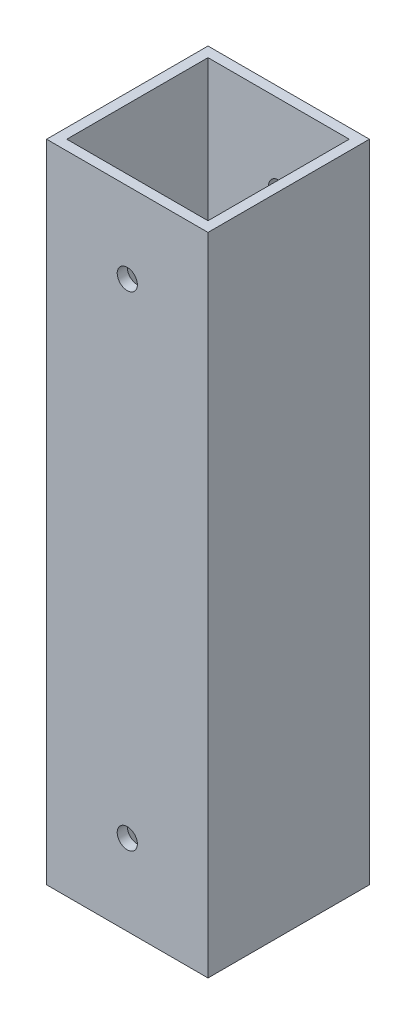
from build123d import *

# Parameters (mm, degrees)
SKETCH1_W           = 25.4
SKETCH1_H           = 25.4
SKETCH1_W_2         = 22.225
SKETCH1_H_2         = 22.225
BOSS_EXTRUDE1_DEPTH = 101.6
SKETCH2_R           = 1.5875
CUT_EXTRUDE1_DEPTH  = 25.4


with BuildPart() as part:
    # Sketch1 → Boss-Extrude1 (new body)
    with BuildSketch(Plane(origin=(0, 0, 0), x_dir=(1, 0, 0), z_dir=(0, 1, 0))):
        Rectangle(SKETCH1_W, SKETCH1_H)
        Rectangle(SKETCH1_W_2, SKETCH1_H_2, mode=Mode.SUBTRACT)
    extrude(amount=BOSS_EXTRUDE1_DEPTH)

    # Sketch2 → Cut-Extrude1 (cut)
    with BuildSketch(Plane(origin=(0, 0, -12.7), x_dir=(-1, 0, 0), z_dir=(0, 0, -1))):
        with Locations((0, 88.9)):
            Circle(SKETCH2_R)
        with Locations((0, 12.7)):
            Circle(SKETCH2_R)
    extrude(amount=-CUT_EXTRUDE1_DEPTH, mode=Mode.SUBTRACT)


solid = part.part
